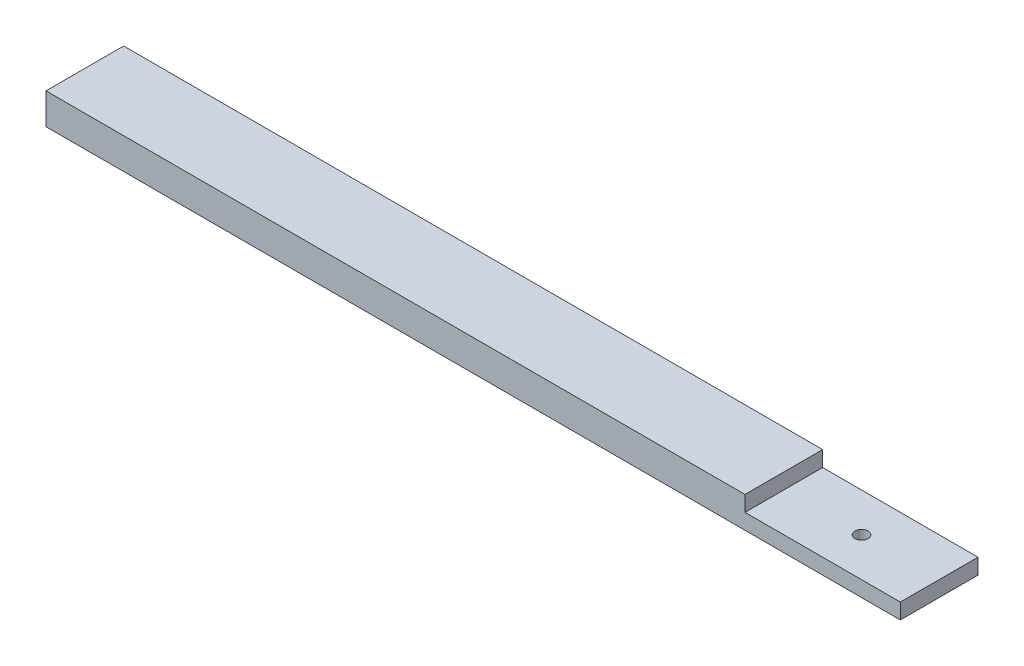
from build123d import *

# Parameters (mm, degrees)
SKETCH1_W           = 139.7
SKETCH1_H           = 12.7
BOSS_EXTRUDE1_DEPTH = 5.08
SKETCH3_W           = 25.4
SKETCH3_H           = 2.54
CUT_EXTRUDE1_DEPTH  = 17.78
SKETCH4_R           = 1.0795
CUT_EXTRUDE2_DEPTH  = 17.78


with BuildPart() as part:
    # Sketch1 → Boss-Extrude1 (new body)
    with BuildSketch(Plane(origin=(0, 0, 0), x_dir=(1, 0, 0), z_dir=(0, 1, 0))):
        Rectangle(SKETCH1_W, SKETCH1_H)
    extrude(amount=BOSS_EXTRUDE1_DEPTH)

    # Sketch3 → Cut-Extrude1 (cut)
    with BuildSketch(Plane.XY.offset(6.35)):
        with Locations((57.15, 3.81)):
            Rectangle(SKETCH3_W, SKETCH3_H)
    extrude(amount=-CUT_EXTRUDE1_DEPTH, mode=Mode.SUBTRACT)

    # Sketch4 → Cut-Extrude2 (cut)
    with BuildSketch(Plane(origin=(0, 2.54, 0), x_dir=(1, 0, 0), z_dir=(0, 1, 0))):
        with Locations((57.15, 0)):
            Circle(SKETCH4_R)
    extrude(amount=-CUT_EXTRUDE2_DEPTH, mode=Mode.SUBTRACT)


solid = part.part
